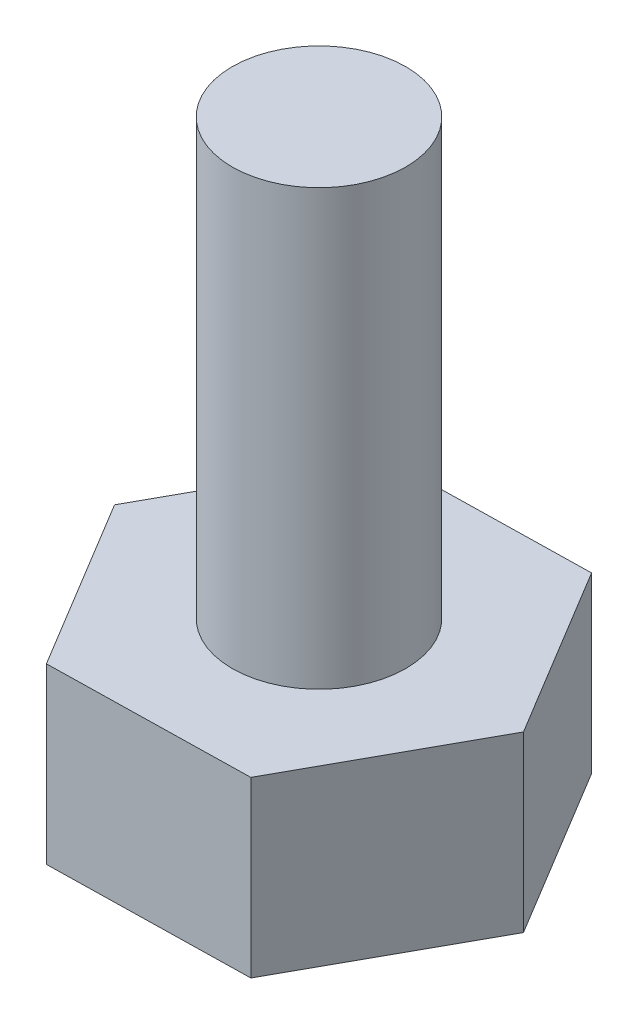
from build123d import *

# Parameters (mm, degrees)
SKETCH1_R           = 2
BOSS_EXTRUDE1_DEPTH = 10
BOSS_EXTRUDE4_DEPTH = 4


with BuildPart() as part:
    # Sketch1 → Boss-Extrude1 (new body)
    with BuildSketch(Plane(origin=(0, 0, 0), x_dir=(1, 0, 0), z_dir=(0, 1, 0))):
        with Locations((-18.876405997, -12.710678642)):
            Circle(SKETCH1_R)
    extrude(amount=BOSS_EXTRUDE1_DEPTH)

    # Sketch4 → Boss-Extrude4 (add)
    with BuildSketch(Plane.XZ):
        Polygon((-16.490145939, 16.665308368), (-21.108085773, 16.754555336), (-23.494345831, 12.79992561), (-21.262666056, 8.756048917), (-16.644726221, 8.666801949), (-14.258466163, 12.621431674), align=None)
    extrude(amount=BOSS_EXTRUDE4_DEPTH)


solid = part.part
